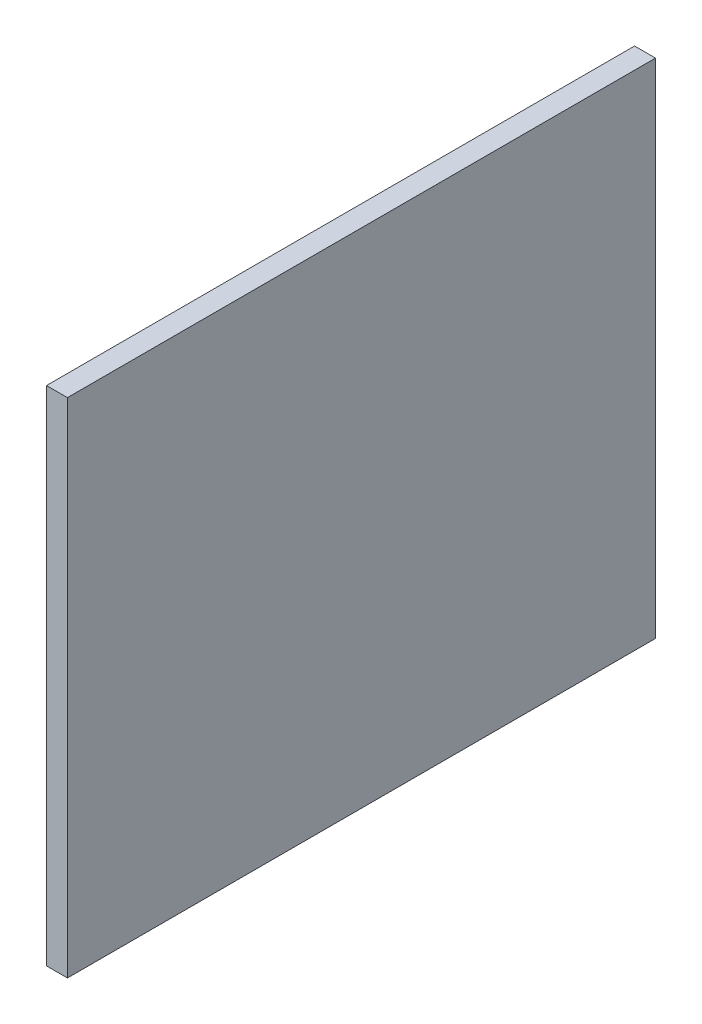
from build123d import *

# Parameters (mm, degrees)
SKETCH2_W           = 89.154
SKETCH2_H           = 76.2
BOSS_EXTRUDE1_DEPTH = 3.175


with BuildPart() as part:
    # Sketch2 → Boss-Extrude1 (new body)
    with BuildSketch(Plane(origin=(0, 0, 0), x_dir=(0, 0, -1), z_dir=(1, 0, 0))):
        with Locations((44.577, 38.1)):
            Rectangle(SKETCH2_W, SKETCH2_H)
    extrude(amount=BOSS_EXTRUDE1_DEPTH)


solid = part.part
